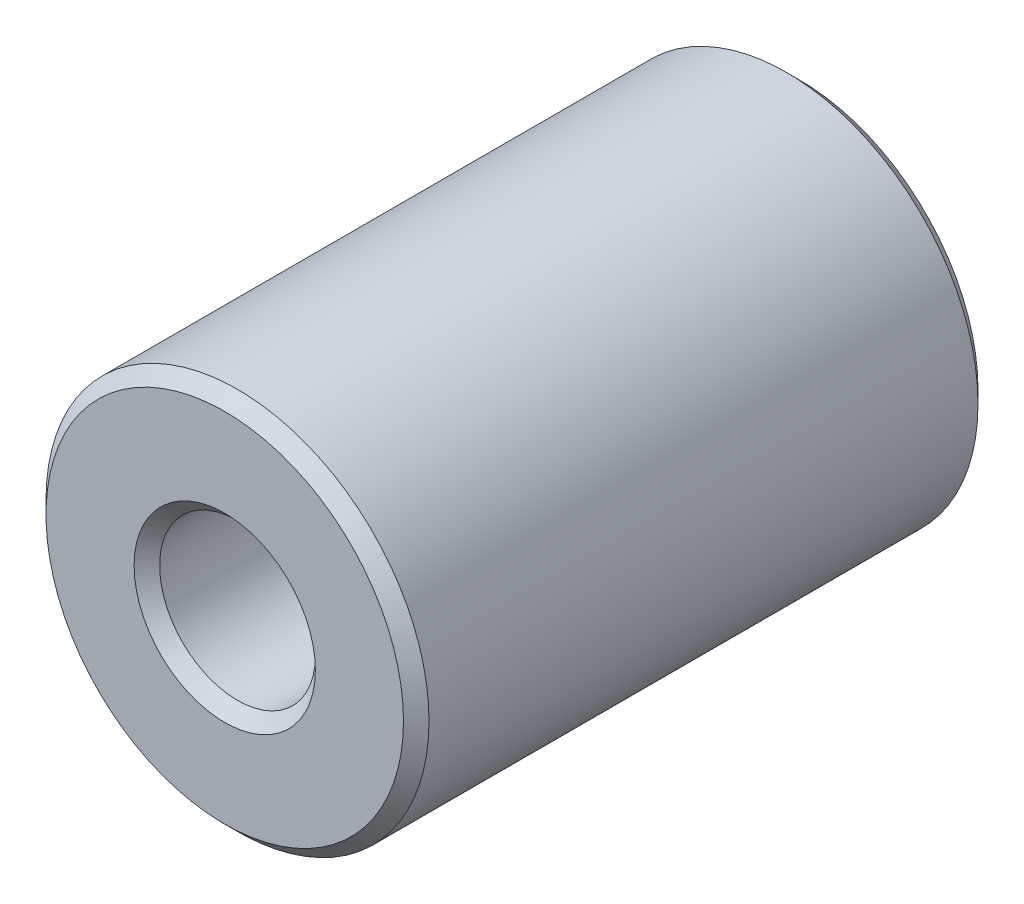
from build123d import *

# Parameters (mm, degrees)
SZKIC1_R                    = 15
SZKIC1_R_2                  = 6.1
DODANIE_WYCI_GNI_CIE1_DEPTH = 45
SFAZOWANIE1_SIZE            = 1


with BuildPart() as part:
    # Szkic1 → Dodanie-wyciągnięcie1 (new body)
    with BuildSketch(Plane.XY):
        Circle(SZKIC1_R)
        Circle(SZKIC1_R_2, mode=Mode.SUBTRACT)
    extrude(amount=DODANIE_WYCI_GNI_CIE1_DEPTH)

    # Sfazowanie1
    sfazowanie1_edges = [part.edges().sort_by_distance(p)[0] for p in [
        (-15, 0, 0),
        (-15, 0, 45),
        (-6.1, 0, 0),
        (-6.1, 0, 45),
    ]]
    chamfer(sfazowanie1_edges, length=SFAZOWANIE1_SIZE)


solid = part.part
